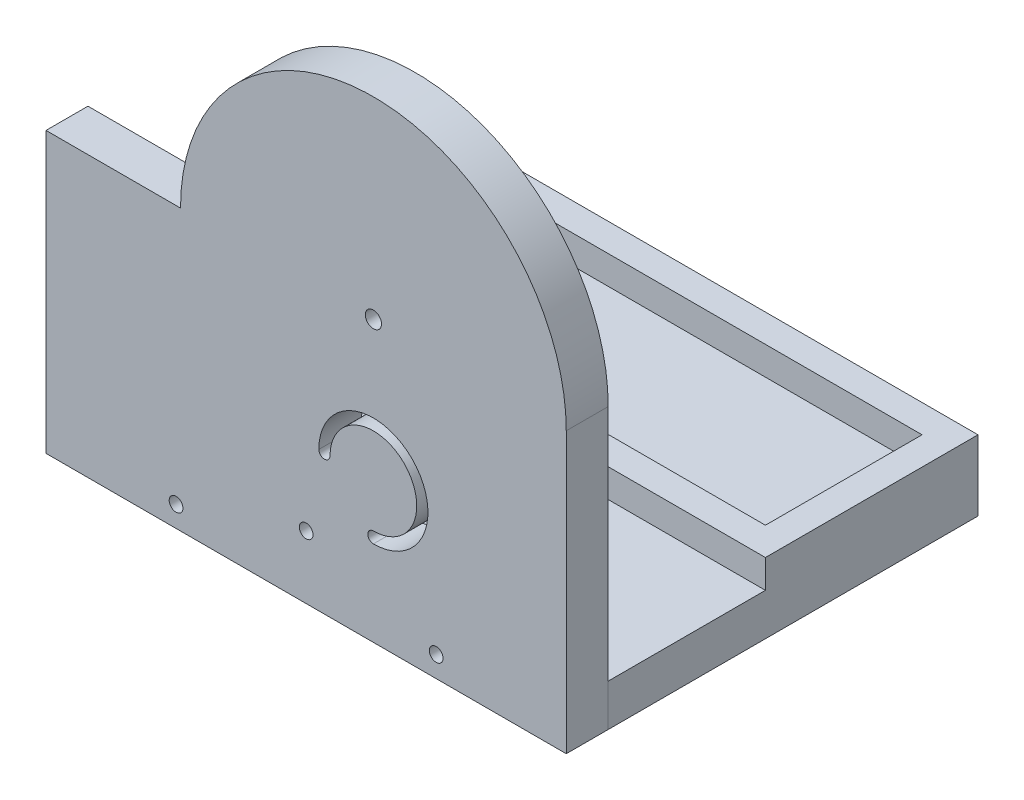
from build123d import *

# Parameters (mm, degrees)
BOSS_EXTRUDE2_DEPTH       = 186
SKETCH3_W                 = 186
SKETCH3_H                 = 76
SKETCH3_W_2               = 166
SKETCH3_H_2               = 56
BOSS_EXTRUDE3_DEPTH       = 10.16
CUT_EXTRUDE5_DEPTH        = 15
M5_CLEARANCE_HOLE1_D      = 5.8
CUT_EXTRUDE6_DEPTH        = 15
BOSS_EXTRUDE4_DEPTH       = 15
F_8_CLEARANCE_HOLE1_D     = 4.9149
F_8_CLEARANCE_HOLE1_DEPTH = 30
F_8_CLEARANCE_HOLE1_TIP   = 1.476584928


with BuildPart() as part:
    # Sketch2 → Boss-Extrude2 (new body)
    with BuildSketch(Plane(origin=(0, 0, 0), x_dir=(0, 0, -1), z_dir=(1, 0, 0))):
        Polygon((-86.851953943, 67.608740711), (-86.851953943, -102.391259289), (60.348046057, -102.391259289), (60.348046057, -87.391259289), (-71.851953943, -87.391259289), (-71.851953943, 67.608740711), align=None)
    extrude(amount=BOSS_EXTRUDE2_DEPTH)

    # Sketch3 → Boss-Extrude3 (add)
    with BuildSketch(Plane(origin=(0, -87.391259289, 0), x_dir=(1, 0, 0), z_dir=(0, 1, 0))):
        with Locations((93, 22.348046057)):
            Rectangle(SKETCH3_W, SKETCH3_H)
        with Locations((93, 22.348046057)):
            Rectangle(SKETCH3_W_2, SKETCH3_H_2, mode=Mode.SUBTRACT)
    extrude(amount=BOSS_EXTRUDE3_DEPTH)

    # Sketch6 → Cut-Extrude5 (cut)
    with BuildSketch(Plane(origin=(0, 0, 71.851953943), x_dir=(-1, 0, 0), z_dir=(0, 0, -1))):
        with BuildLine():
            ThreePointArc((-97.544250495, -52.391259289), (-130.832832728, -38.602677055), (-117.044250495, -71.891259289))
            ThreePointArc((-117.044250495, -71.891259289), (-115.044250495, -69.891259289), (-117.044250495, -67.891259289))
            ThreePointArc((-117.044250495, -67.891259289), (-128.004405604, -41.43110418), (-101.544250495, -52.391259289))
            ThreePointArc((-101.544250495, -52.391259289), (-99.544250495, -54.391259289), (-97.544250495, -52.391259289))
        make_face()
    extrude(amount=-CUT_EXTRUDE5_DEPTH, mode=Mode.SUBTRACT)

    # M5 Clearance Hole1 (through all)
    with Locations(Plane(origin=(117.044250495, -2.391259289, 71.851953943), x_dir=(-1, 0, 0), z_dir=(0, 0, -1))):
        with Locations((0, 0)):
            Hole(M5_CLEARANCE_HOLE1_D / 2)

    # Sketch13 → Cut-Extrude6 (cut)
    with BuildSketch(Plane(origin=(0, 0, 71.851953943), x_dir=(-1, 0, 0), z_dir=(0, 0, -1))):
        with BuildLine():
            Line((-48.088500991, -2.391259289), (0, -2.391259289))
            Line((0, -2.391259289), (0, 67.608740711))
            Line((0, 67.608740711), (-186, 67.608740711))
            Line((-186, 67.608740711), (-186, -2.391259289))
            ThreePointArc((-186, -2.391259289), (-117.044250495, 66.564490216), (-48.088500991, -2.391259289))
        make_face()
    extrude(amount=-CUT_EXTRUDE6_DEPTH, mode=Mode.SUBTRACT)

    # Sketch16 → Boss-Extrude4 (add)
    with BuildSketch(Plane(origin=(0, 0, 71.851953943), x_dir=(-1, 0, 0), z_dir=(0, 0, -1))):
        with BuildLine():
            Line((-100.5, -79.891259289), (-100.5, -87.391259289))
            Line((-100.5, -87.391259289), (-85.5, -87.391259289))
            Line((-85.5, -87.391259289), (-85.5, -79.891259289))
            ThreePointArc((-85.5, -79.891259289), (-93, -72.391259289), (-100.5, -79.891259289))
        make_face()
    extrude(amount=BOSS_EXTRUDE4_DEPTH)

    # #8 Clearance Hole1
    with Locations(Plane(origin=(46.5, -94.891259289, 86.851953943), x_dir=(0, 1, 0), z_dir=(0, 0, 1))):
        with Locations((0, 0), (15, -46.5), (0, -93)):
            Hole(F_8_CLEARANCE_HOLE1_D / 2, depth=F_8_CLEARANCE_HOLE1_DEPTH)
            with Locations((0, 0, -(F_8_CLEARANCE_HOLE1_DEPTH + F_8_CLEARANCE_HOLE1_TIP / 2))):  # 118° drill point
                Cone(0, F_8_CLEARANCE_HOLE1_D / 2, F_8_CLEARANCE_HOLE1_TIP, mode=Mode.SUBTRACT)


with BuildPart() as body_2:
    # Split2: the piece on the far side of the plane
    add(part.part)
    split(bisect_by=Plane(origin=(0, 0, 71.851953943), x_dir=(-1, 0, 0), z_dir=(0, 0, -1)), keep=Keep.BOTTOM)


with BuildPart() as part_1:
    add(part.part)

    # Split2
    split(bisect_by=Plane(origin=(0, 0, 71.851953943), x_dir=(-1, 0, 0), z_dir=(0, 0, -1)), keep=Keep.TOP)


solid = Compound([body_2.part, part_1.part])
